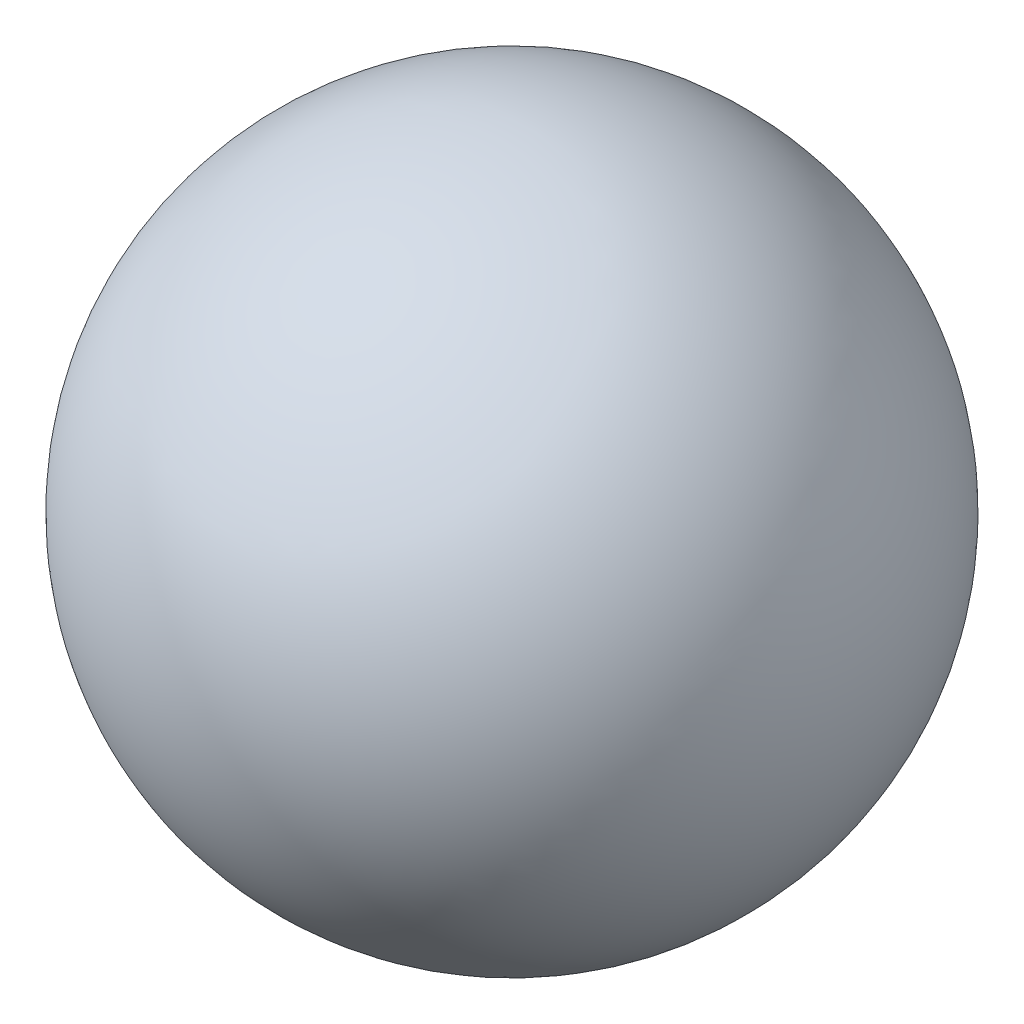
from build123d import *


with BuildPart() as part:
    # Sketch2 → Revolve11 (revolve)
    with BuildSketch(Plane(origin=(0, 0, 0), x_dir=(1, 0, 0), z_dir=(0, 1, 0))):
        with BuildLine():
            Line((0, 1.5875), (0, -1.5875))
            ThreePointArc((0, -1.5875), (1.5875, 0), (0, 1.5875))
        make_face()
    revolve(axis=Axis((0, 0, -1.5875), (0, 0, 1)))


solid = part.part
